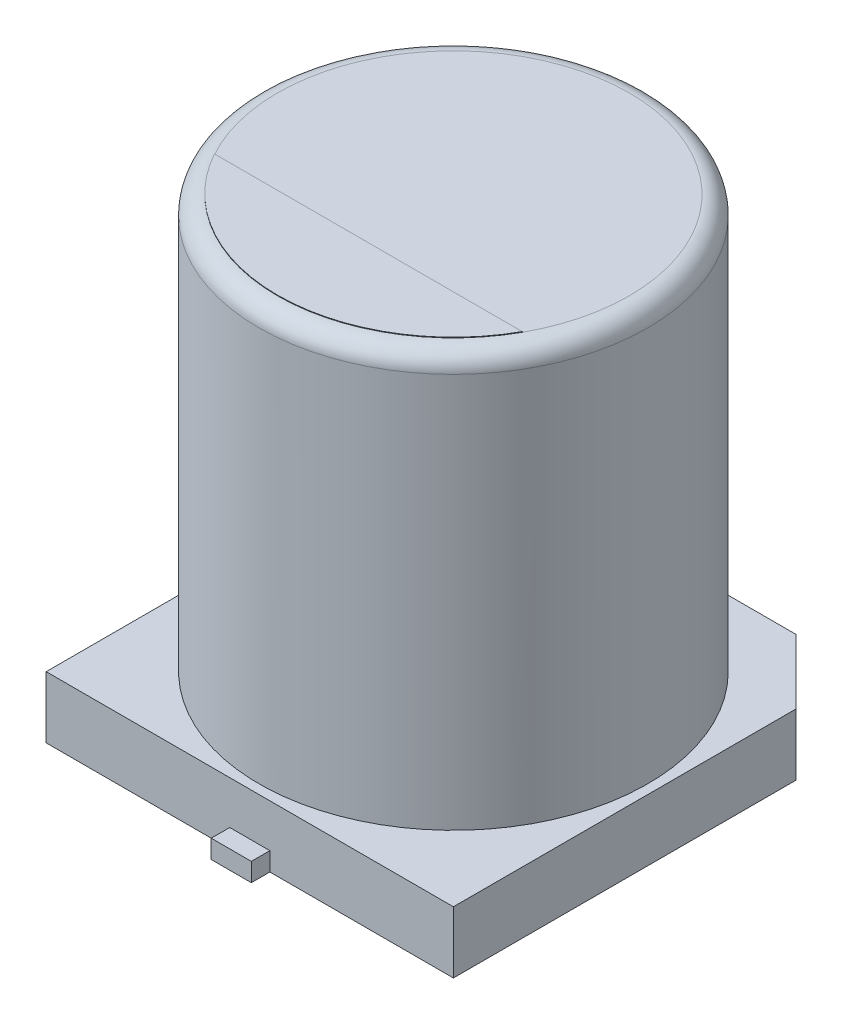
from build123d import *

# Parameters (mm, degrees)
BOSS_EXTRUDE1_DEPTH = 1
SKETCH3_R           = 3.15
BOSS_EXTRUDE2_DEPTH = 7.7
FILLET1_R           = 0.3
SKETCH4_W           = 0.65
SKETCH4_H           = 2.8
BOSS_EXTRUDE3_DEPTH = 0.3
BOSS_EXTRUDE4_DEPTH = 0.01


with BuildPart() as part:
    # Sketch2 → Boss-Extrude1 (new body)
    with BuildSketch(Plane(origin=(0, 0, 0), x_dir=(1, 0, 0), z_dir=(0, 1, 0))):
        Polygon((3.3, -3.3), (-3.3, -3.3), (-3.3, 2.25), (-2.25, 3.3), (2.25, 3.3), (3.3, 2.25), align=None)
    extrude(amount=BOSS_EXTRUDE1_DEPTH)

    # Sketch3 → Boss-Extrude2 (add)
    with BuildSketch(Plane(origin=(0, 0, 0), x_dir=(1, 0, 0), z_dir=(0, 1, 0))):
        Circle(SKETCH3_R)
    extrude(amount=BOSS_EXTRUDE2_DEPTH)

    # Fillet1
    fillet1_edges = [part.edges().sort_by_distance(p)[0] for p in [
        (-3.15, 7.7, 0),
    ]]
    fillet(fillet1_edges, radius=FILLET1_R)

    # Sketch4 → Boss-Extrude3 (add)
    with BuildSketch(Plane(origin=(0, 0, 0), x_dir=(1, 0, 0), z_dir=(0, 1, 0))):
        with Locations((0, 2.2)):
            Rectangle(SKETCH4_W, SKETCH4_H)
        with Locations((0, -2.2)):
            Rectangle(SKETCH4_W, SKETCH4_H)
    extrude(amount=BOSS_EXTRUDE3_DEPTH)

    # Sketch5 → Boss-Extrude4 (add)
    with BuildSketch(Plane(origin=(0, 7.7, 0), x_dir=(1, 0, 0), z_dir=(0, 1, 0))):
        with BuildLine():
            Line((-2.494581862, -1.378245745), (2.494581862, -1.378245745))
            ThreePointArc((2.494581862, -1.378245745), (0, -2.85), (-2.494581862, -1.378245745))
        make_face()
    extrude(amount=BOSS_EXTRUDE4_DEPTH)


solid = part.part
